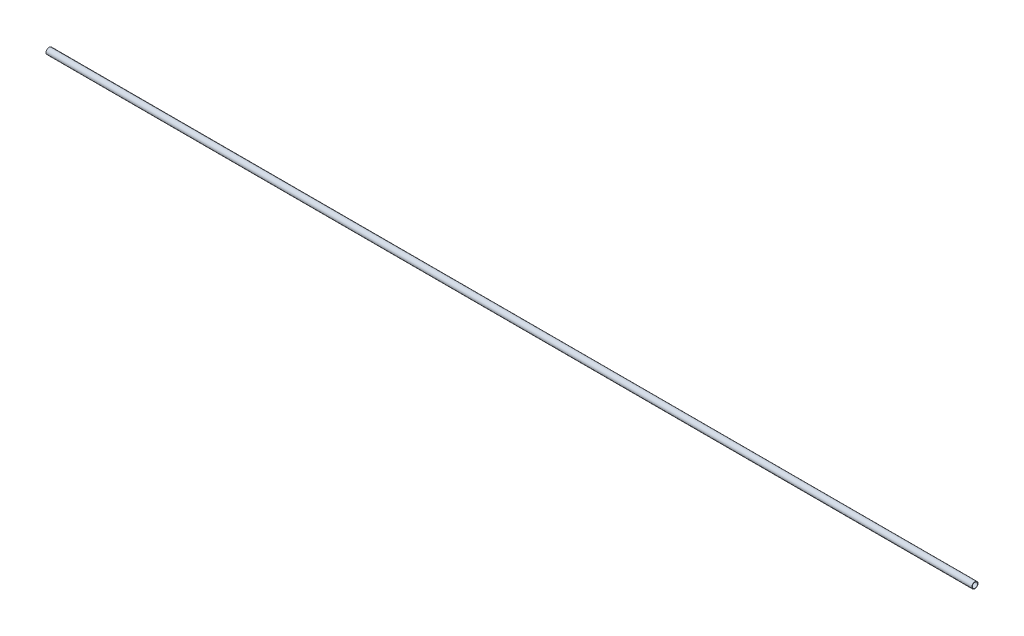
from build123d import *

# Parameters (mm, degrees)
SKETCH2_R   = 2.38125
SKETCH2_R_2 = 2.02565


with BuildPart() as part:
    # Sweep1: sweep along a path in Sketch1
    with BuildLine(Plane(origin=(0, 0, 0), x_dir=(1, 0, 0), z_dir=(0, 1, 0))) as sweep1_path:
        Line((0, 0), (711.2, 0))
    # Sketch2 → Sweep1 (sweep)
    with BuildSketch(Plane(origin=(0, 0, 0), x_dir=(0, 0, -1), z_dir=(1, 0, 0))):
        Circle(SKETCH2_R)
        Circle(SKETCH2_R_2, mode=Mode.SUBTRACT)
    sweep(path=sweep1_path.line)


solid = part.part
